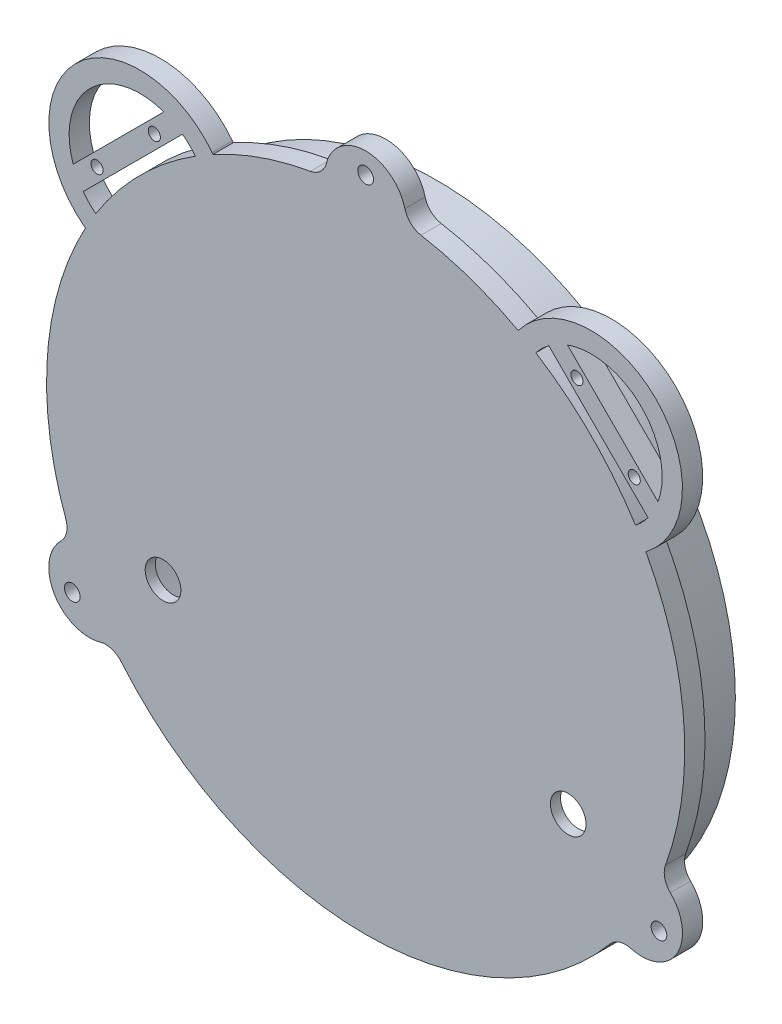
from build123d import *

# Parameters (mm, degrees)
SKETCH1_R                        = 100.0125
EXTRUDE1_DEPTH                   = 6.35
SKETCH2_R                        = 93.6625
EXTRUDE2_DEPTH                   = 15.875
SKETCH3_R                        = 87.3125
CUT_EXTRUDE1_DEPTH               = 19.05
EXTRUDE3_DEPTH                   = 6.35
SKETCH5_R                        = 5.588
CUT_EXTRUDE2_DEPTH               = 153.317295267
F_10_0_1935_DIAMETER_HOLE1_D     = 4.9149
F_10_0_1935_DIAMETER_HOLE1_DEPTH = 330.2
F_10_0_1935_DIAMETER_HOLE1_TIP   = 1.476584928
FILLET1_R                        = 6.35
BOSS_EXTRUDE1_DEPTH              = 6.35
BOSS_EXTRUDE2_DEPTH              = 6.35
F_6_CLEARANCE_HOLE1_AT_2_COUNT   = 2
F_6_CLEARANCE_HOLE1_AT_2_PITCH   = 25.4


with BuildPart() as part:
    # Sketch1 → Extrude1 (new body)
    with BuildSketch(Plane.XY):
        Circle(SKETCH1_R)
    extrude(amount=EXTRUDE1_DEPTH)

    # Sketch2 → Extrude2 (add)
    with BuildSketch(Plane(origin=(0, 0, 0), x_dir=(-1, 0, 0), z_dir=(0, 0, -1))):
        with Locations(Location((0, 0, 0), (0, 0, 180))):
            Circle(SKETCH2_R)
    extrude(amount=EXTRUDE2_DEPTH)

    # Sketch3 → Cut-Extrude1 (cut)
    with BuildSketch(Plane(origin=(0, 0, -15.875), x_dir=(-1, 0, 0), z_dir=(0, 0, -1))):
        Circle(SKETCH3_R)
    extrude(amount=-CUT_EXTRUDE1_DEPTH, mode=Mode.SUBTRACT)

    # Sketch8 → Extrude3 (add)
    with BuildSketch(Plane.XY.offset(6.35)):
        with BuildLine():
            ThreePointArc((-12.674375762, 99.206150794), (0, 112.7125), (12.674375762, 99.206150794))
            ThreePointArc((12.674375762, 99.206150794), (0, 100.0125), (-12.674375762, 99.206150794))
        make_face()
        with BuildLine():
            ThreePointArc((92.25223468, -38.62674401), (97.611888324, -56.35625), (79.577858918, -60.579406784))
            ThreePointArc((79.577858918, -60.579406784), (86.613365696, -50.00625), (92.25223468, -38.62674401))
        make_face()
        with BuildLine():
            ThreePointArc((-92.25223468, -38.62674401), (-97.611888324, -56.35625), (-79.577858918, -60.579406784))
            ThreePointArc((-79.577858918, -60.579406784), (-86.613365696, -50.00625), (-92.25223468, -38.62674401))
        make_face()
    extrude(amount=-EXTRUDE3_DEPTH)

    # Sketch5 → Cut-Extrude2 (cut, through all)
    with BuildSketch(Plane.XY.offset(6.35)):
        with Locations((-63.5, -35.56)):
            Circle(SKETCH5_R)
        with Locations((63.5, -35.56)):
            Circle(SKETCH5_R)
    extrude(amount=-CUT_EXTRUDE2_DEPTH, mode=Mode.SUBTRACT)

    # #10 (0.1935) Diameter Hole1
    with Locations(Plane(origin=(0, 106.172778556, 6.35), x_dir=(1, 0, 0), z_dir=(0, 0, 1))):
        with Locations((0, 0), (91.94832342, -159.259167834), (-91.94832342, -159.259167834)):
            Hole(F_10_0_1935_DIAMETER_HOLE1_D / 2, depth=F_10_0_1935_DIAMETER_HOLE1_DEPTH)
            with Locations((0, 0, -(F_10_0_1935_DIAMETER_HOLE1_DEPTH + F_10_0_1935_DIAMETER_HOLE1_TIP / 2))):  # 118° drill point
                Cone(0, F_10_0_1935_DIAMETER_HOLE1_D / 2, F_10_0_1935_DIAMETER_HOLE1_TIP, mode=Mode.SUBTRACT)

    # Fillet1
    fillet1_edges = [part.edges().sort_by_distance(p)[0] for p in [
        (12.674375762, 99.206150794, 3.175),
        (-12.674375762, 99.206150794, 3.175),
        (79.577858918, -60.579406784, 3.175),
        (92.25223468, -38.62674401, 3.175),
        (-92.25223468, -38.62674401, 3.175),
        (-79.577858918, -60.579406784, 3.175),
    ]]
    fillet(fillet1_edges, radius=FILLET1_R)

    # Sketch25 → Boss-Extrude1 (add)
    with BuildSketch(Plane.XY.offset(6.35)):
        with BuildLine():
            ThreePointArc((-84.312132199, 53.135676765), (-86.434965165, 86.434965165), (-53.135676765, 84.312132199))
            ThreePointArc((-53.135676765, 84.312132199), (-48.681897417, 83.741957207), (-48.111722425, 88.195736555))
            ThreePointArc((-48.111722425, 88.195736555), (-90.925093226, 90.925093226), (-88.195736555, 48.111722425))
            ThreePointArc((-88.195736555, 48.111722425), (-83.741957207, 48.681897417), (-84.312132199, 53.135676765))
        make_face()
    boss_extrude1 = extrude(amount=-BOSS_EXTRUDE1_DEPTH)

    # Sketch26 → Boss-Extrude2 (add)
    with BuildSketch(Plane.XY.offset(6.35)):
        Polygon((-93.170157256, 61.739260832), (-61.739260832, 93.170157256), (-57.249132772, 88.680029196), (-88.680029196, 57.249132772), align=None)
    boss_extrude2 = extrude(amount=-BOSS_EXTRUDE2_DEPTH)

    # Sketch27 → #6 Clearance Hole1 (revolve, cut)
    with BuildSketch(Plane(origin=(-84.189901135, 66.229388893, 6.35), x_dir=(0, -1, 0), z_dir=(1, 0, 0))):
        Polygon((0, 0), (0, 26.540824014), (1.89865, 25.4), (1.89865, 0), align=None)
    f_6_clearance_hole1 = revolve(axis=Axis((-84.189901135, 66.229388893, 12.7), (0, 0, -1)), mode=Mode.SUBTRACT)

    # #6 Clearance Hole1 at 2: #6 Clearance Hole1 ×2
    with Locations(*[Vector(0.7071067811865465, 0.7071067811865487, 0) * (i * F_6_CLEARANCE_HOLE1_AT_2_PITCH) for i in range(1, F_6_CLEARANCE_HOLE1_AT_2_COUNT)]):
        add(f_6_clearance_hole1, mode=Mode.SUBTRACT)

    # Mirror1: Boss-Extrude1, Boss-Extrude2, #6 Clearance Hole1 across plane
    add(boss_extrude1.mirror(Plane(origin=(0, 0, 0), x_dir=(0, 0, 1), z_dir=(1, 0, 0))))
    add(boss_extrude2.mirror(Plane(origin=(0, 0, 0), x_dir=(0, 0, 1), z_dir=(1, 0, 0))))
    add(f_6_clearance_hole1.mirror(Plane(origin=(0, 0, 0), x_dir=(0, 0, 1), z_dir=(1, 0, 0))), mode=Mode.SUBTRACT)

    # Mirror1 copy 1 sketch → Mirror1 copy 1 (revolve, cut)
    with BuildSketch(Plane(origin=(66.229388893, 84.189901135, 6.35), x_dir=(0, -1, 0), z_dir=(-1, 0, 0))):
        Polygon((0, 0), (0, -26.540824014), (1.89865, -25.4), (1.89865, 0), align=None)
    revolve(axis=Axis((66.229388893, 84.189901135, 12.7), (0, 0, 1)), mode=Mode.SUBTRACT)


solid = part.part
